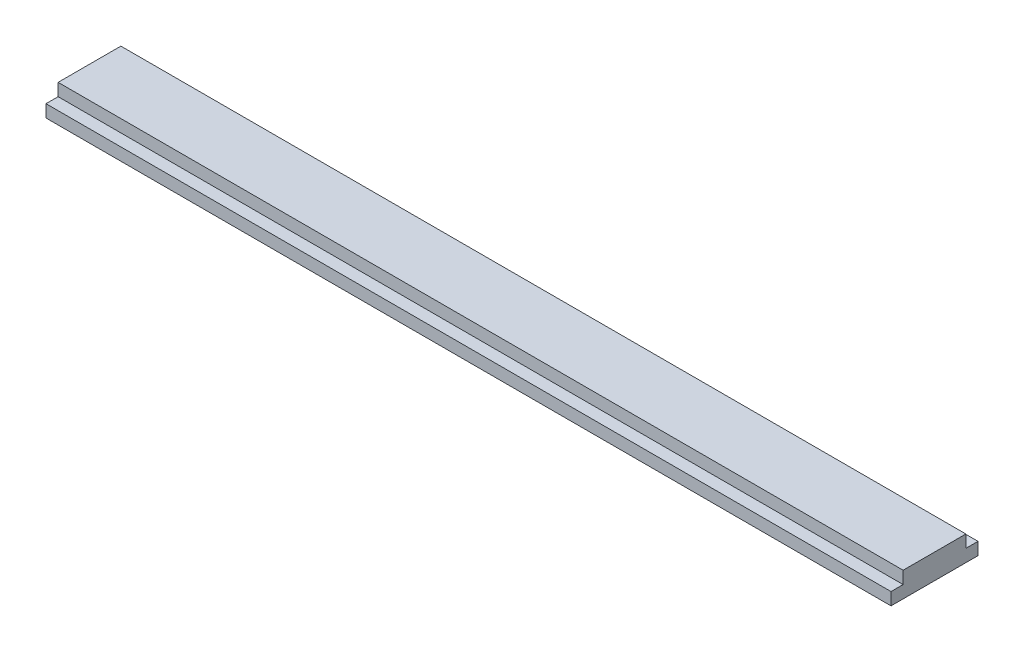
from build123d import *

# Parameters (mm, degrees)
SKETCH2_W            = 136
SKETCH2_H            = 10.1
MIDDLE_EXTRUDE_DEPTH = 4
SKETCH2_4_W          = 136
SKETCH2_4_H          = 1.95
MAIN_EXTRUDE_DEPTH   = 2


with BuildPart() as part:
    # Sketch2 → Middle Extrude (new body)
    with BuildSketch(Plane(origin=(0, 0, 0), x_dir=(1, 0, 0), z_dir=(0, 1, 0))):
        Rectangle(SKETCH2_W, SKETCH2_H)
    extrude(amount=MIDDLE_EXTRUDE_DEPTH)

    # Sketch2_4 → Main Extrude (add)
    with BuildSketch(Plane(origin=(0, 0, 0), x_dir=(1, 0, 0), z_dir=(0, 1, 0))):
        with Locations((0, 6.025)):
            Rectangle(SKETCH2_4_W, SKETCH2_4_H)
        with Locations((0, -6.025)):
            Rectangle(SKETCH2_4_W, SKETCH2_4_H)
    extrude(amount=MAIN_EXTRUDE_DEPTH)


solid = part.part
